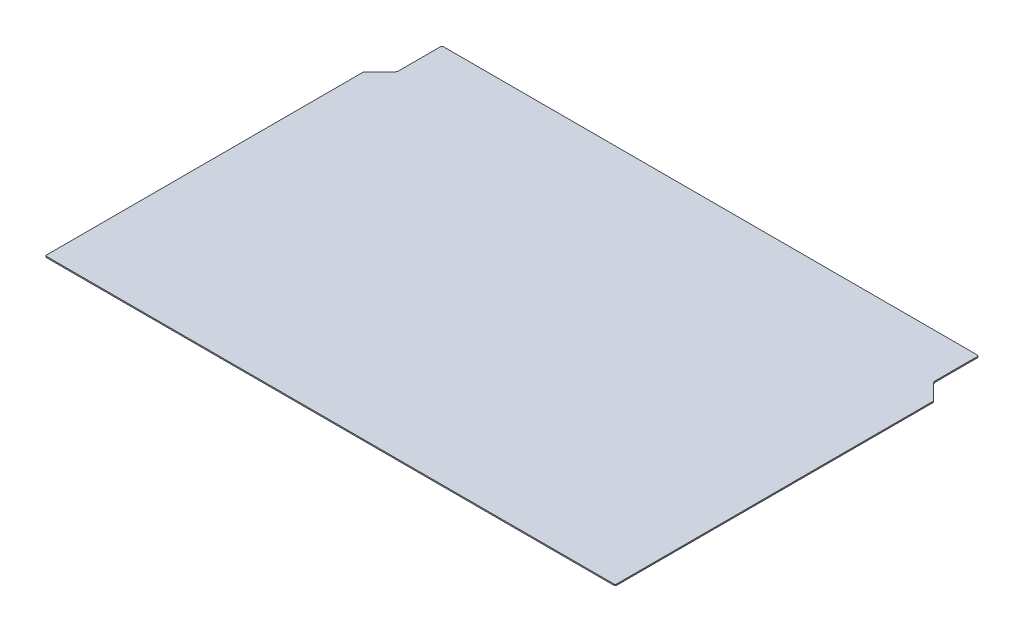
from build123d import *

# Parameters (mm, degrees)
BOSS_EXTRUDE1_DEPTH = 3.175


with BuildPart() as part:
    # Sketch1 → Boss-Extrude1 (new body)
    with BuildSketch(Plane(origin=(0, 0, 0), x_dir=(1, 0, 0), z_dir=(0, 1, 0))):
        with BuildLine():
            Line((-717.55, 504.825), (-717.55, 392.610512242))
            ThreePointArc((-717.55, 392.610512242), (-718.516729937, 387.750432651), (-721.269743879, 383.630256121))
            Line((-721.269743879, 383.630256121), (-761.07006403, 343.82993597))
            ThreePointArc((-761.07006403, 343.82993597), (-761.758317516, 342.799891837), (-762, 341.584871939))
            Line((-762, 341.584871939), (-762, -504.825))
            ThreePointArc((-762, -504.825), (-761.07006403, -507.07006403), (-758.825, -508))
            Line((-758.825, -508), (758.825, -508))
            ThreePointArc((758.825, -508), (761.07006403, -507.07006403), (762, -504.825))
            Line((762, -504.825), (762, 341.584871939))
            ThreePointArc((762, 341.584871939), (761.758317516, 342.799891837), (761.07006403, 343.82993597))
            Line((761.07006403, 343.82993597), (721.269743879, 383.630256121))
            ThreePointArc((721.269743879, 383.630256121), (718.516729937, 387.750432651), (717.55, 392.610512242))
            Line((717.55, 392.610512242), (717.55, 504.825))
            ThreePointArc((717.55, 504.825), (716.62006403, 507.07006403), (714.375, 508))
            Line((714.375, 508), (-714.375, 508))
            ThreePointArc((-714.375, 508), (-716.62006403, 507.07006403), (-717.55, 504.825))
        make_face()
    extrude(amount=BOSS_EXTRUDE1_DEPTH)


solid = part.part
